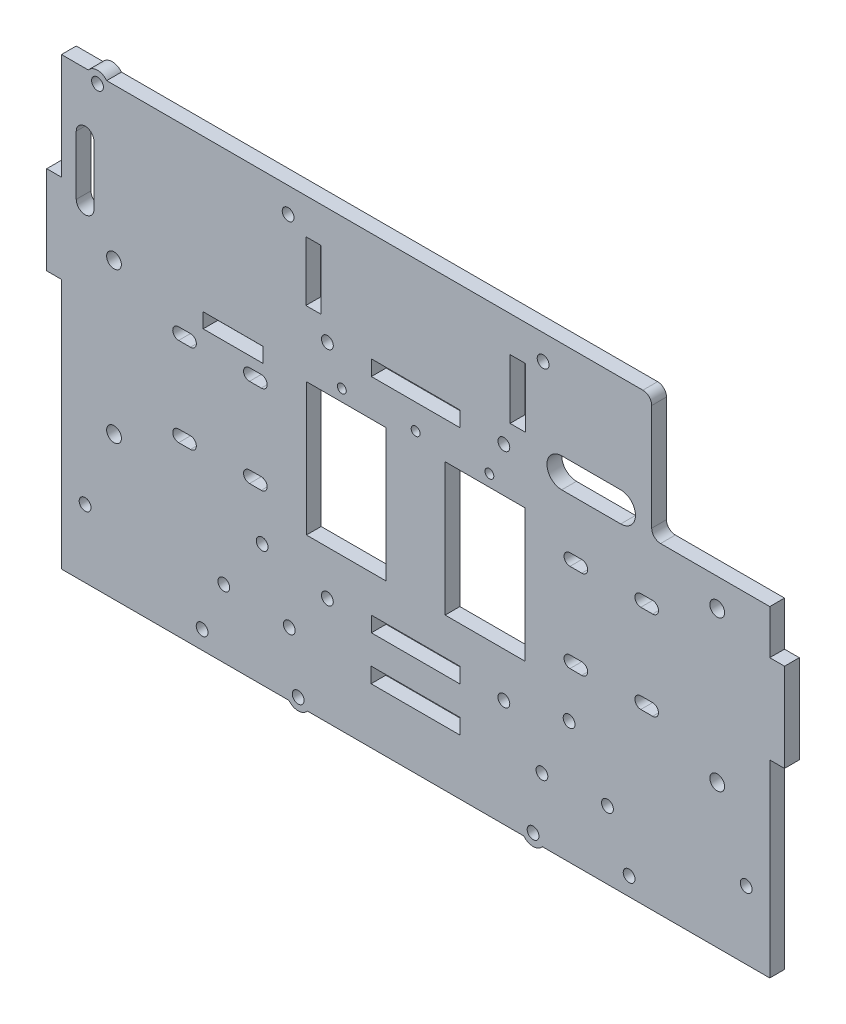
from build123d import *

# Parameters (mm, degrees)
SKETCH1_W           = 240
SKETCH1_H           = 151
BOSS_EXTRUDE1_DEPTH = 5
SKETCH2_W           = 27
SKETCH2_H           = 45
CUT_EXTRUDE1_DEPTH  = 10
CUT_EXTRUDE10_DEPTH = 5
SKETCH15_R          = 2.5
CUT_EXTRUDE11_DEPTH = 10
SKETCH17_R          = 2
SKETCH17_W          = 30
SKETCH17_H          = 5.2
CUT_EXTRUDE13_DEPTH = 10
SKETCH20_R          = 2
CUT_EXTRUDE15_DEPTH = 5
SKETCH23_R          = 2
CUT_EXTRUDE16_DEPTH = 5
SKETCH24_W          = 30.2
SKETCH24_H          = 5.2
CUT_EXTRUDE17_DEPTH = 5
SKETCH27_R          = 1.5
CUT_EXTRUDE20_DEPTH = 10
SKETCH28_R          = 2
CUT_EXTRUDE21_DEPTH = 10
SKETCH31_R          = 2
CUT_EXTRUDE24_DEPTH = 10
SKETCH32_R          = 2
CUT_EXTRUDE25_DEPTH = 10
SKETCH34_W          = 40
SKETCH34_H          = 42
CUT_EXTRUDE26_DEPTH = 10
CUT_EXTRUDE27_DEPTH = 10
CUT_EXTRUDE28_DEPTH = 10
SKETCH37_W          = 5.2
SKETCH37_H          = 20.2
CUT_EXTRUDE29_DEPTH = 10
SKETCH38_W          = 20.2
SKETCH38_H          = 5.02
CUT_EXTRUDE30_DEPTH = 5
SKETCH39_R          = 2
CUT_EXTRUDE31_DEPTH = 5
SKETCH40_R          = 4
SKETCH40_R_2        = 2
BOSS_EXTRUDE6_DEPTH = 5
FILLET1_R           = 3
SKETCH41_R          = 2
CUT_EXTRUDE32_DEPTH = 5
SKETCH42_R          = 4
SKETCH42_R_2        = 2
BOSS_EXTRUDE7_DEPTH = 5
SKETCH43_W          = 5
SKETCH43_H          = 30
BOSS_EXTRUDE8_DEPTH = 5
FILLET2_R           = 3


with BuildPart() as part:
    # Sketch1 → Boss-Extrude1 (new body)
    with BuildSketch(Plane.XY):
        Rectangle(SKETCH1_W, SKETCH1_H)
    extrude(amount=BOSS_EXTRUDE1_DEPTH)

    # Sketch2 → Cut-Extrude1 (cut)
    with BuildSketch(Plane(origin=(0, 0, 0), x_dir=(-1, 0, 0), z_dir=(0, 0, -1))):
        with Locations((23.5, -1.5)):
            Rectangle(SKETCH2_W, SKETCH2_H)
        with Locations((-23.5, -1.5)):
            Rectangle(SKETCH2_W, SKETCH2_H)
    extrude(amount=-CUT_EXTRUDE1_DEPTH, mode=Mode.SUBTRACT)

    # Sketch14 → Cut-Extrude10 (cut)
    with BuildSketch(Plane(origin=(0, 0, 0), x_dir=(-1, 0, 0), z_dir=(0, 0, -1))):
        with BuildLine():
            Line((-56.3, 15.46), (-52.3, 15.46))
            ThreePointArc((-52.3, 15.46), (-50.3, 13.46), (-52.3, 11.46))
            Line((-52.3, 11.46), (-56.3, 11.46))
            ThreePointArc((-56.3, 11.46), (-58.3, 13.46), (-56.3, 15.46))
        make_face()
        with BuildLine():
            Line((-80.3, 15.46), (-76.3, 15.46))
            ThreePointArc((-76.3, 15.46), (-74.3, 13.46), (-76.3, 11.46))
            Line((-76.3, 11.46), (-80.3, 11.46))
            ThreePointArc((-80.3, 11.46), (-82.3, 13.46), (-80.3, 15.46))
        make_face()
        with BuildLine():
            Line((-80.3, -14.54), (-76.3, -14.54))
            ThreePointArc((-76.3, -14.54), (-74.3, -16.54), (-76.3, -18.54))
            Line((-76.3, -18.54), (-80.3, -18.54))
            ThreePointArc((-80.3, -18.54), (-82.3, -16.54), (-80.3, -14.54))
        make_face()
        with BuildLine():
            Line((-56.3, -14.54), (-52.3, -14.54))
            ThreePointArc((-52.3, -14.54), (-50.3, -16.54), (-52.3, -18.54))
            Line((-52.3, -18.54), (-56.3, -18.54))
            ThreePointArc((-56.3, -18.54), (-58.3, -16.54), (-56.3, -14.54))
        make_face()
        with BuildLine():
            Line((56.3, -14.54), (52.3, -14.54))
            ThreePointArc((52.3, -14.54), (50.3, -16.54), (52.3, -18.54))
            Line((52.3, -18.54), (56.3, -18.54))
            ThreePointArc((56.3, -18.54), (58.3, -16.54), (56.3, -14.54))
        make_face()
        with BuildLine():
            Line((80.3, -14.54), (76.3, -14.54))
            ThreePointArc((76.3, -14.54), (74.3, -16.54), (76.3, -18.54))
            Line((76.3, -18.54), (80.3, -18.54))
            ThreePointArc((80.3, -18.54), (82.3, -16.54), (80.3, -14.54))
        make_face()
        with BuildLine():
            Line((80.3, 15.46), (76.3, 15.46))
            ThreePointArc((76.3, 15.46), (74.3, 13.46), (76.3, 11.46))
            Line((76.3, 11.46), (80.3, 11.46))
            ThreePointArc((80.3, 11.46), (82.3, 13.46), (80.3, 15.46))
        make_face()
        with BuildLine():
            Line((56.3, 15.46), (52.3, 15.46))
            ThreePointArc((52.3, 15.46), (50.3, 13.46), (52.3, 11.46))
            Line((52.3, 11.46), (56.3, 11.46))
            ThreePointArc((56.3, 11.46), (58.3, 13.46), (56.3, 15.46))
        make_face()
    extrude(amount=-CUT_EXTRUDE10_DEPTH, mode=Mode.SUBTRACT)

    # Sketch15 → Cut-Extrude11 (cut)
    with BuildSketch(Plane(origin=(0, 0, 0), x_dir=(-1, 0, 0), z_dir=(0, 0, -1))):
        with Locations((-102.2, -27)):
            Circle(SKETCH15_R)
        with Locations((-102.2, 24)):
            Circle(SKETCH15_R)
        with Locations((102.2, 24)):
            Circle(SKETCH15_R)
        with Locations((102.2, -27)):
            Circle(SKETCH15_R)
    extrude(amount=-CUT_EXTRUDE11_DEPTH, mode=Mode.SUBTRACT)

    # Sketch17 → Cut-Extrude13 (cut)
    with BuildSketch(Plane(origin=(0, 0, 0), x_dir=(-1, 0, 0), z_dir=(0, 0, -1))):
        with Locations((-29.9, -39.1)):
            Circle(SKETCH17_R)
        with Locations((29.9, -39.1)):
            Circle(SKETCH17_R)
        with Locations((-29.9, 36.1)):
            Circle(SKETCH17_R)
        with Locations((29.9, 36.1)):
            Circle(SKETCH17_R)
        with Locations((0, 36.1)):
            Rectangle(SKETCH17_W, SKETCH17_H)
        with Locations((0, -39.1)):
            Rectangle(SKETCH17_W, SKETCH17_H)
    extrude(amount=-CUT_EXTRUDE13_DEPTH, mode=Mode.SUBTRACT)

    # Sketch20 → Cut-Extrude15 (cut)
    with BuildSketch(Plane(origin=(0, 0, 0), x_dir=(-1, 0, 0), z_dir=(0, 0, -1))):
        with Locations((43.2, 67)):
            Circle(SKETCH20_R)
        with Locations((-43.2, 67)):
            Circle(SKETCH20_R)
    extrude(amount=-CUT_EXTRUDE15_DEPTH, mode=Mode.SUBTRACT)

    # Sketch23 → Cut-Extrude16 (cut)
    with BuildSketch(Plane(origin=(0, 0, 0), x_dir=(-1, 0, 0), z_dir=(0, 0, -1))):
        with Locations((42.8, -54)):
            Circle(SKETCH23_R)
        with Locations((-42.8, -54)):
            Circle(SKETCH23_R)
    extrude(amount=-CUT_EXTRUDE16_DEPTH, mode=Mode.SUBTRACT)

    # Sketch24 → Cut-Extrude17 (cut)
    with BuildSketch(Plane(origin=(0, 0, 0), x_dir=(-1, 0, 0), z_dir=(0, 0, -1))):
        with Locations((0, -54.1)):
            Rectangle(SKETCH24_W, SKETCH24_H)
    extrude(amount=-CUT_EXTRUDE17_DEPTH, mode=Mode.SUBTRACT)

    # Sketch27 → Cut-Extrude20 (cut)
    with BuildSketch(Plane(origin=(0, 0, 0), x_dir=(-1, 0, 0), z_dir=(0, 0, -1))):
        with Locations((-25, 25)):
            Circle(SKETCH27_R)
        with Locations((0, 25)):
            Circle(SKETCH27_R)
        with Locations((25, 25)):
            Circle(SKETCH27_R)
    extrude(amount=-CUT_EXTRUDE20_DEPTH, mode=Mode.SUBTRACT)

    # Sketch28 → Cut-Extrude21 (cut)
    with BuildSketch(Plane.XY.offset(5)):
        with Locations((112, -52.5)):
            Circle(SKETCH28_R)
        with Locations((65, -52.5)):
            Circle(SKETCH28_R)
        with Locations((-65, -52.5)):
            Circle(SKETCH28_R)
        with Locations((-112, -52.5)):
            Circle(SKETCH28_R)
    extrude(amount=-CUT_EXTRUDE21_DEPTH, mode=Mode.SUBTRACT)

    # Sketch31 → Cut-Extrude24 (cut)
    with BuildSketch(Plane(origin=(0, 0, 0), x_dir=(-1, 0, 0), z_dir=(0, 0, -1))):
        with Locations((72.345744872, -69.339745962)):
            Circle(SKETCH31_R)
        with Locations((-72.345744872, -69.339745962)):
            Circle(SKETCH31_R)
    extrude(amount=-CUT_EXTRUDE24_DEPTH, mode=Mode.SUBTRACT)

    # Sketch32 → Cut-Extrude25 (cut)
    with BuildSketch(Plane(origin=(0, 0, 0), x_dir=(-1, 0, 0), z_dir=(0, 0, -1))):
        with Locations((52.005844325, -34.1100048)):
            Circle(SKETCH32_R)
        with Locations((-52.005844325, -34.1100048)):
            Circle(SKETCH32_R)
    extrude(amount=-CUT_EXTRUDE25_DEPTH, mode=Mode.SUBTRACT)

    # Sketch34 → Cut-Extrude26 (cut)
    with BuildSketch(Plane(origin=(0, 0, 0), x_dir=(-1, 0, 0), z_dir=(0, 0, -1))):
        with Locations((-100, 54.5)):
            Rectangle(SKETCH34_W, SKETCH34_H)
    extrude(amount=-CUT_EXTRUDE26_DEPTH, mode=Mode.SUBTRACT)

    # Sketch35 → Cut-Extrude27 (cut)
    with BuildSketch(Plane(origin=(0, 0, 0), x_dir=(-1, 0, 0), z_dir=(0, 0, -1))):
        with BuildLine():
            Line((-49.5, 32.5), (-69.5, 32.5))
            ThreePointArc((-69.5, 32.5), (-74.5, 37.5), (-69.5, 42.5))
            Line((-69.5, 42.5), (-49.5, 42.5))
            ThreePointArc((-49.5, 42.5), (-44.5, 37.5), (-49.5, 32.5))
        make_face()
    extrude(amount=-CUT_EXTRUDE27_DEPTH, mode=Mode.SUBTRACT)

    # Sketch36 → Cut-Extrude28 (cut)
    with BuildSketch(Plane(origin=(0, 0, 0), x_dir=(-1, 0, 0), z_dir=(0, 0, -1))):
        with BuildLine():
            Line((109, 35.5), (109, 55.5))
            ThreePointArc((109, 55.5), (112, 58.5), (115, 55.5))
            Line((115, 55.5), (115, 35.5))
            ThreePointArc((115, 35.5), (112, 32.5), (109, 35.5))
        make_face()
    extrude(amount=-CUT_EXTRUDE28_DEPTH, mode=Mode.SUBTRACT)

    # Sketch37 → Cut-Extrude29 (cut)
    with BuildSketch(Plane.XY.offset(5)):
        with Locations((34.6, 53.35)):
            Rectangle(SKETCH37_W, SKETCH37_H)
        with Locations((-34.6, 53.35)):
            Rectangle(SKETCH37_W, SKETCH37_H)
    extrude(amount=-CUT_EXTRUDE29_DEPTH, mode=Mode.SUBTRACT)

    # Sketch38 → Cut-Extrude30 (cut)
    with BuildSketch(Plane.XY.offset(5)):
        with Locations((-61.9, 21.51)):
            Rectangle(SKETCH38_W, SKETCH38_H)
    extrude(amount=-CUT_EXTRUDE30_DEPTH, mode=Mode.SUBTRACT)

    # Sketch39 → Cut-Extrude31 (cut)
    with BuildSketch(Plane(origin=(0, 0, 0), x_dir=(-1, 0, 0), z_dir=(0, 0, -1))):
        with Locations((107.8, 73)):
            Circle(SKETCH39_R)
    extrude(amount=-CUT_EXTRUDE31_DEPTH, mode=Mode.SUBTRACT)

    # Sketch40 → Boss-Extrude6 (add)
    with BuildSketch(Plane(origin=(0, 0, 0), x_dir=(-1, 0, 0), z_dir=(0, 0, -1))):
        with Locations((107.8, 73)):
            Circle(SKETCH40_R)
        with Locations((107.8, 73)):
            Circle(SKETCH40_R_2, mode=Mode.SUBTRACT)
    extrude(amount=-BOSS_EXTRUDE6_DEPTH)

    # Fillet1
    fillet1_edges = [part.edges().sort_by_distance(p)[0] for p in [
        (80, 33.5, 2.5),
    ]]
    fillet(fillet1_edges, radius=FILLET1_R)

    # Sketch41 → Cut-Extrude32 (cut)
    with BuildSketch(Plane(origin=(0, 0, 0), x_dir=(-1, 0, 0), z_dir=(0, 0, -1))):
        with Locations((39.8, -73)):
            Circle(SKETCH41_R)
        with Locations((-39.8, -73)):
            Circle(SKETCH41_R)
    extrude(amount=-CUT_EXTRUDE32_DEPTH, mode=Mode.SUBTRACT)

    # Sketch42 → Boss-Extrude7 (add)
    with BuildSketch(Plane(origin=(0, 0, 0), x_dir=(-1, 0, 0), z_dir=(0, 0, -1))):
        with Locations((-39.8, -73)):
            Circle(SKETCH42_R)
        with Locations((-39.8, -73)):
            Circle(SKETCH42_R_2, mode=Mode.SUBTRACT)
        with Locations((39.8, -73)):
            Circle(SKETCH42_R)
        with Locations((39.8, -73)):
            Circle(SKETCH42_R_2, mode=Mode.SUBTRACT)
    extrude(amount=-BOSS_EXTRUDE7_DEPTH)

    # Sketch43 → Boss-Extrude8 (add)
    with BuildSketch(Plane(origin=(0, 0, 0), x_dir=(-1, 0, 0), z_dir=(0, 0, -1))):
        with Locations((-122.5, 3.5)):
            Rectangle(SKETCH43_W, SKETCH43_H)
        with Locations((122.5, 24.5)):
            Rectangle(SKETCH43_W, SKETCH43_H)
    extrude(amount=-BOSS_EXTRUDE8_DEPTH)

    # Fillet2
    fillet2_edges = [part.edges().sort_by_distance(p)[0] for p in [
        (80, 75.5, 2.5),
    ]]
    fillet(fillet2_edges, radius=FILLET2_R)


solid = part.part
